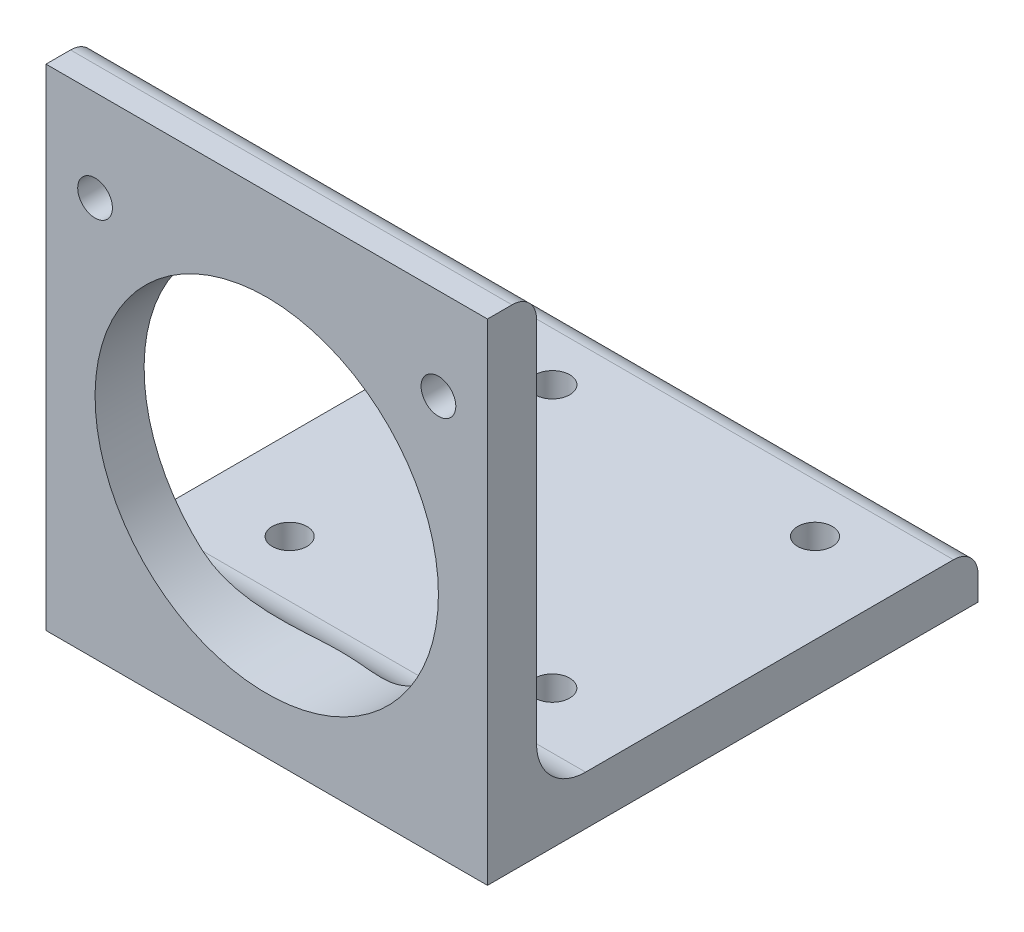
from build123d import *

# Parameters (mm, degrees)
BOSS_EXTRUDE1_DEPTH   = 57.15
M4_CLEARANCE_HOLE1_D  = 4.5
SKETCH7_R             = 22.225
CUT_EXTRUDE1_DEPTH    = 28.575
F_8_CLEARANCE_HOLE1_D = 4.4958


with BuildPart() as part:
    # Sketch1 → Boss-Extrude1 (new body)
    with BuildSketch(Plane(origin=(0, 0, 0), x_dir=(0, 0, -1), z_dir=(1, 0, 0))):
        with BuildLine():
            Line((3.175, -19.05), (3.175, 28.575))
            ThreePointArc((3.175, 28.575), (2.24506403, 30.82006403), (0, 31.75))
            Line((0, 31.75), (-3.175, 31.75))
            Line((-3.175, 31.75), (-3.175, -31.75))
            Line((-3.175, -31.75), (60.325, -31.75))
            Line((60.325, -31.75), (60.325, -28.575))
            ThreePointArc((60.325, -28.575), (59.39506403, -26.32993597), (57.15, -25.4))
            Line((57.15, -25.4), (9.525, -25.4))
            ThreePointArc((9.525, -25.4), (5.034871939, -23.540128061), (3.175, -19.05))
        make_face()
    extrude(amount=BOSS_EXTRUDE1_DEPTH)

    # M4 Clearance Hole1 (through all)
    with Locations(Plane(origin=(0, -31.75, 0), x_dir=(-1, 0, 0), z_dir=(0, -1, 0))):
        with Locations((-45.575, 50.8), (-11.575, 50.8), (-11.575, 16.7894), (-45.575, 16.7894)):
            Hole(M4_CLEARANCE_HOLE1_D / 2)

    # Sketch7 → Cut-Extrude1 (cut, symmetric)
    with BuildSketch(Plane(origin=(0, 0, -3.175), x_dir=(-1, 0, 0), z_dir=(0, 0, -1))):
        with Locations(Location((-28.575, -2.3114, 0), (0, 0, 311.136639748))):  # turned: the seam where the file's is
            Circle(SKETCH7_R)
    extrude(amount=CUT_EXTRUDE1_DEPTH, both=True, mode=Mode.SUBTRACT)

    # #8 Clearance Hole1 (through all)
    with Locations(Plane(origin=(0, 0, -3.175), x_dir=(-1, 0, 0), z_dir=(0, 0, -1))):
        with Locations((-50.8, 19.9136), (-6.35, 19.9136)):
            Hole(F_8_CLEARANCE_HOLE1_D / 2)


solid = part.part
